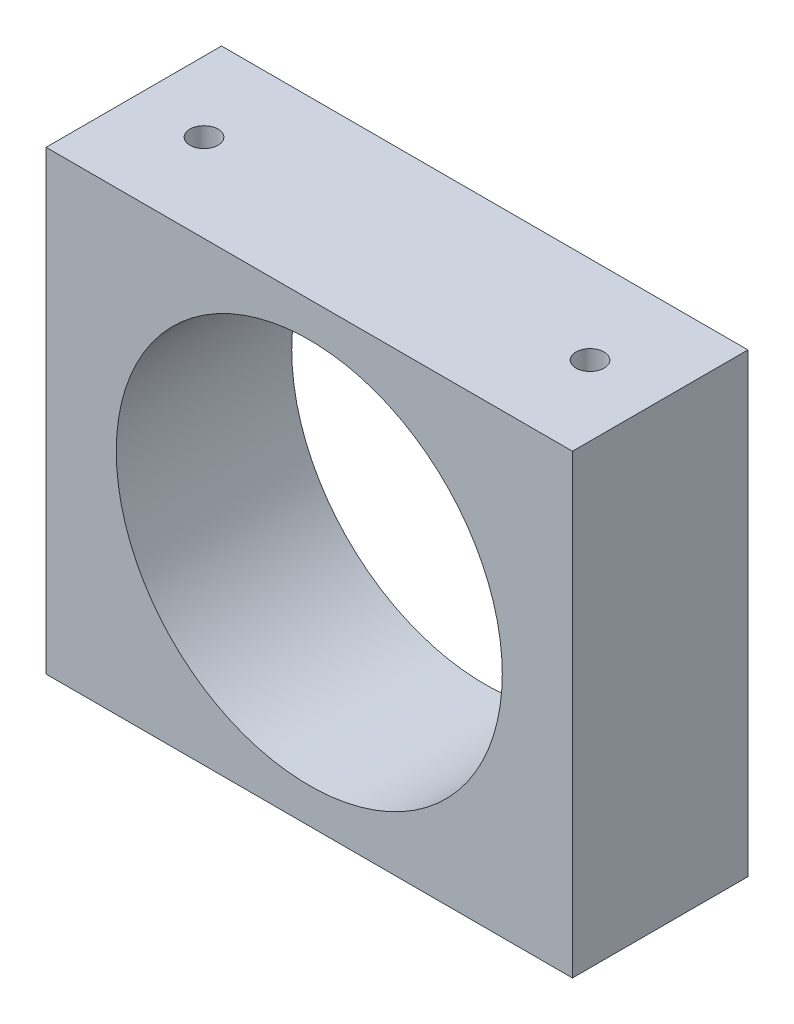
from build123d import *

# Parameters (mm, degrees)
ESQUISSE1_W                                   = 30
ESQUISSE1_H                                   = 26
ESQUISSE1_R                                   = 11
BOSS_EXTRU_1_DEPTH                            = 10
TROU_POUR_TARAUDAGE_POUR_TROU_TARAUD_M2_D     = 1.6
TROU_POUR_TARAUDAGE_POUR_TROU_TARAUD_M2_DEPTH = 5
TROU_POUR_TARAUDAGE_POUR_TROU_TARAUD_M2_TIP   = 0.480688495
TROU_POUR_TARAUDAGE_POUR_TROU_TARAUD_2_D      = 1.6
TROU_POUR_TARAUDAGE_POUR_TROU_TARAUD_2_DEPTH  = 5
TROU_POUR_TARAUDAGE_POUR_TROU_TARAUD_2_TIP    = 0.480688495


with BuildPart() as part:
    # Esquisse1 → Boss.-Extru.1 (new body)
    with BuildSketch(Plane.XY):
        with Locations((15, 13)):
            Rectangle(ESQUISSE1_W, ESQUISSE1_H)
        with Locations((15, 13)):
            Circle(ESQUISSE1_R, mode=Mode.SUBTRACT)
    extrude(amount=BOSS_EXTRU_1_DEPTH)

    # Trou pour taraudage pour trou taraud_ M2
    with Locations(Plane(origin=(0, 26, 0), x_dir=(1, 0, 0), z_dir=(0, 1, 0))):
        with Locations((4, -5), (26, -5)):
            Hole(TROU_POUR_TARAUDAGE_POUR_TROU_TARAUD_M2_D / 2, depth=TROU_POUR_TARAUDAGE_POUR_TROU_TARAUD_M2_DEPTH)
            with Locations((0, 0, -(TROU_POUR_TARAUDAGE_POUR_TROU_TARAUD_M2_DEPTH + TROU_POUR_TARAUDAGE_POUR_TROU_TARAUD_M2_TIP / 2))):  # 118° drill point
                Cone(0, TROU_POUR_TARAUDAGE_POUR_TROU_TARAUD_M2_D / 2, TROU_POUR_TARAUDAGE_POUR_TROU_TARAUD_M2_TIP, mode=Mode.SUBTRACT)

    # Trou pour taraudage pour trou taraud 2
    with Locations(Plane(origin=(0, 0, 0), x_dir=(-1, 0, 0), z_dir=(0, -1, 0))):
        with Locations((-4, -5), (-26, -5)):
            Hole(TROU_POUR_TARAUDAGE_POUR_TROU_TARAUD_2_D / 2, depth=TROU_POUR_TARAUDAGE_POUR_TROU_TARAUD_2_DEPTH)
            with Locations((0, 0, -(TROU_POUR_TARAUDAGE_POUR_TROU_TARAUD_2_DEPTH + TROU_POUR_TARAUDAGE_POUR_TROU_TARAUD_2_TIP / 2))):  # 118° drill point
                Cone(0, TROU_POUR_TARAUDAGE_POUR_TROU_TARAUD_2_D / 2, TROU_POUR_TARAUDAGE_POUR_TROU_TARAUD_2_TIP, mode=Mode.SUBTRACT)


solid = part.part
